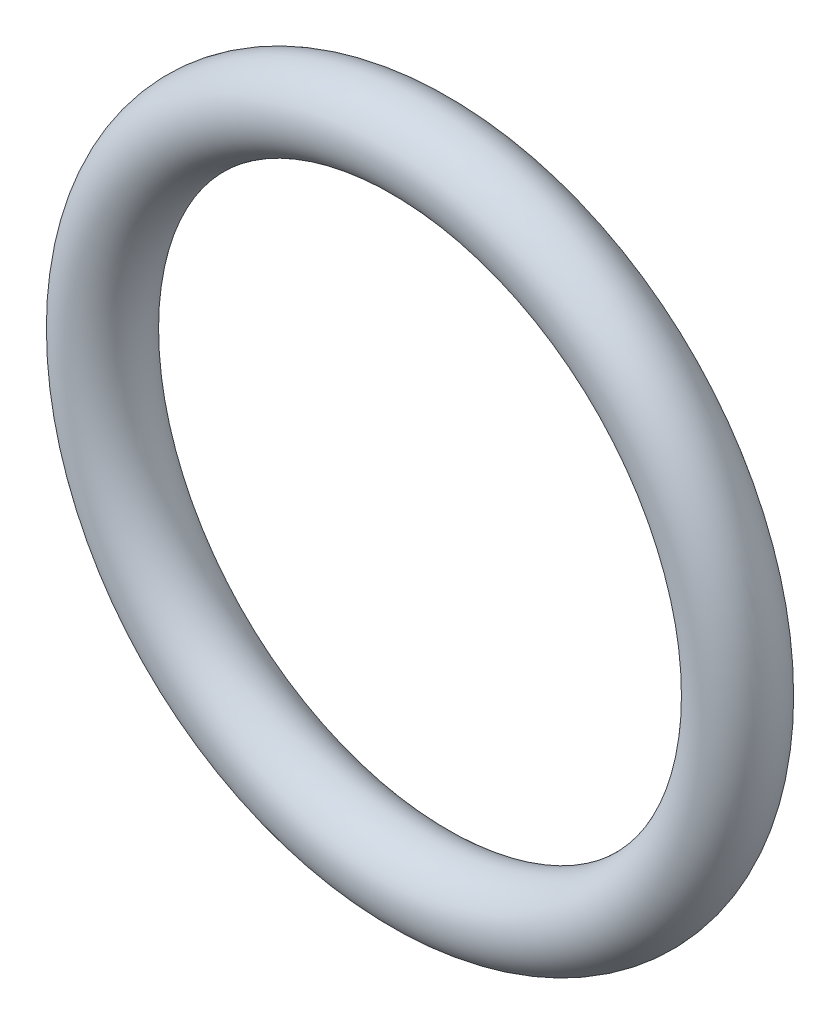
from build123d import *

# Parameters (mm, degrees)
SKETCH1_R = 0.5


with BuildPart() as part:
    # Sketch1 → Revolve1 (revolve)
    with BuildSketch(Plane(origin=(0, 0, 0), x_dir=(0, -1, 0), z_dir=(1, 0, 0))):
        with Locations((4, 0)):
            Circle(SKETCH1_R)
    revolve(axis=Axis((0, 0, 0.5), (0, 0, -1)))


solid = part.part
